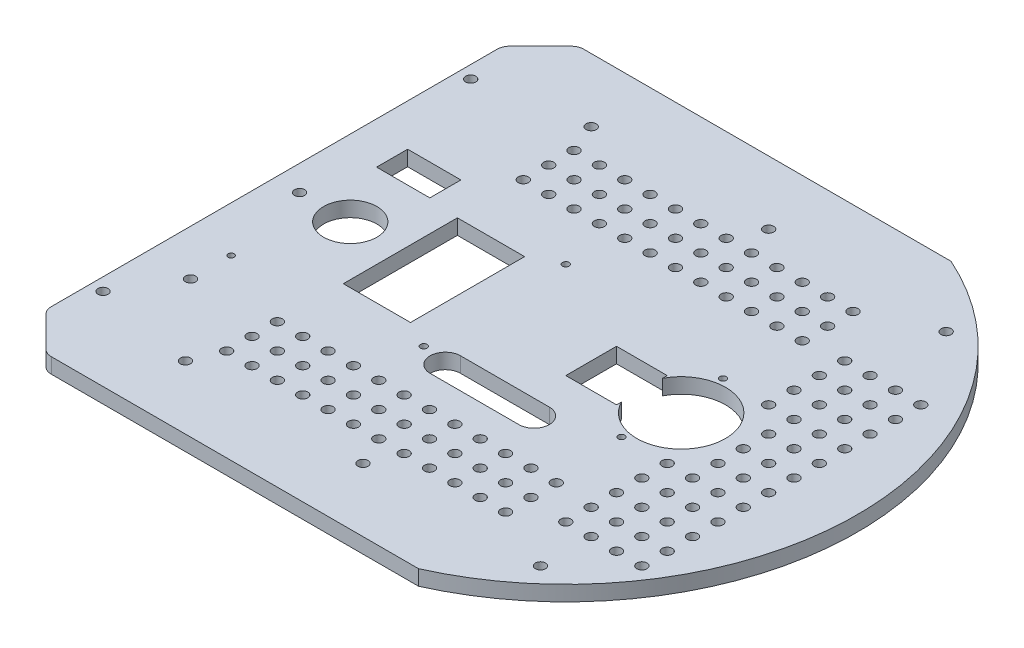
from build123d import *

# Parameters (mm, degrees)
SKETCH1_R           = 2
BOSS_EXTRUDE1_DEPTH = 6
SKETCH2_R           = 1.3
SKETCH2_R_2         = 10.5
SKETCH2_R_3         = 1.2
SKETCH2_R_4         = 2
SKETCH2_R_5         = 17.5
SKETCH2_W           = 26.5
SKETCH2_H           = 45
CUT_EXTRUDE1_DEPTH  = 10
BOSS_EXTRUDE2_DEPTH = 6
CHAMFER1_SIZE       = 15
FILLET1_R           = 5
SKETCH4_R           = 2
CUT_EXTRUDE2_DEPTH  = 10
SKETCH5_W           = 21
SKETCH5_H           = 12.25
CUT_EXTRUDE3_DEPTH  = 10
SKETCH6_W           = 20
SKETCH6_H           = 20
CUT_EXTRUDE4_DEPTH  = 10


with BuildPart() as part:
    # Sketch1 → Boss-Extrude1 (new body)
    with BuildSketch(Plane(origin=(0, 0, 0), x_dir=(1, 0, 0), z_dir=(0, 1, 0))):
        with BuildLine():
            Line((-46.904157598, -105), (46.904157598, -105))
            ThreePointArc((46.904157598, -105), (115, 0), (46.904157598, 105))
            Line((46.904157598, 105), (-46.904157598, 105))
            ThreePointArc((-46.904157598, 105), (-115, 0), (-46.904157598, -105))
        make_face()
        with Locations((-70, 80)):
            Circle(SKETCH1_R, mode=Mode.SUBTRACT)
        with Locations((70, 80)):
            Circle(SKETCH1_R, mode=Mode.SUBTRACT)
        with Locations((70, -80)):
            Circle(SKETCH1_R, mode=Mode.SUBTRACT)
        with Locations((-70, -80)):
            Circle(SKETCH1_R, mode=Mode.SUBTRACT)
        with Locations((0, 80)):
            Circle(SKETCH1_R, mode=Mode.SUBTRACT)
        with Locations((70, 0)):
            Circle(SKETCH1_R, mode=Mode.SUBTRACT)
        with Locations((0, -80)):
            Circle(SKETCH1_R, mode=Mode.SUBTRACT)
    extrude(amount=BOSS_EXTRUDE1_DEPTH)

    # Sketch2 → Cut-Extrude1 (cut)
    with BuildSketch(Plane(origin=(0, 6, 0), x_dir=(1, 0, 0), z_dir=(0, 1, 0))):
        with Locations((-28, 28)):
            Circle(SKETCH2_R)
        with Locations((-28, -28)):
            Circle(SKETCH2_R)
        with Locations((42, 20)):
            Circle(SKETCH2_R)
        with Locations((42, -20)):
            Circle(SKETCH2_R)
        with Locations((-85, 0)):
            Circle(SKETCH2_R_2)
        with Locations((-97, -35)):
            Circle(SKETCH2_R_3)
        with Locations((-97, -51)):
            Circle(SKETCH2_R_4)
        with Locations((-105, 0)):
            Circle(SKETCH2_R_4)
        with Locations((60, 50)):
            Circle(SKETCH2_R_4)
        with Locations((70, 50)):
            Circle(SKETCH2_R_4)
        with Locations((80, 50)):
            Circle(SKETCH2_R_4)
        with Locations((90, 50)):
            Circle(SKETCH2_R_4)
        with Locations((70, 40)):
            Circle(SKETCH2_R_4)
        with Locations((80, 40)):
            Circle(SKETCH2_R_4)
        with Locations((90, 40)):
            Circle(SKETCH2_R_4)
        with Locations((70, 30)):
            Circle(SKETCH2_R_4)
        with Locations((80, 30)):
            Circle(SKETCH2_R_4)
        with Locations((90, 30)):
            Circle(SKETCH2_R_4)
        with Locations((70, 20)):
            Circle(SKETCH2_R_4)
        with Locations((80, 20)):
            Circle(SKETCH2_R_4)
        with Locations((90, 20)):
            Circle(SKETCH2_R_4)
        with Locations((70, 10)):
            Circle(SKETCH2_R_4)
        with Locations((80, 10)):
            Circle(SKETCH2_R_4)
        with Locations((90, 10)):
            Circle(SKETCH2_R_4)
        with Locations((70, 0)):
            Circle(SKETCH2_R_4)
        with Locations((80, 0)):
            Circle(SKETCH2_R_4)
        with Locations((90, 0)):
            Circle(SKETCH2_R_4)
        with Locations((70, -10)):
            Circle(SKETCH2_R_4)
        with Locations((80, -10)):
            Circle(SKETCH2_R_4)
        with Locations((90, -10)):
            Circle(SKETCH2_R_4)
        with Locations((70, -20)):
            Circle(SKETCH2_R_4)
        with Locations((80, -20)):
            Circle(SKETCH2_R_4)
        with Locations((90, -20)):
            Circle(SKETCH2_R_4)
        with Locations((70, -30)):
            Circle(SKETCH2_R_4)
        with Locations((80, -30)):
            Circle(SKETCH2_R_4)
        with Locations((90, -30)):
            Circle(SKETCH2_R_4)
        with Locations((70, -40)):
            Circle(SKETCH2_R_4)
        with Locations((80, -40)):
            Circle(SKETCH2_R_4)
        with Locations((90, -40)):
            Circle(SKETCH2_R_4)
        with Locations((70, -50)):
            Circle(SKETCH2_R_4)
        with Locations((80, -50)):
            Circle(SKETCH2_R_4)
        with Locations((90, -50)):
            Circle(SKETCH2_R_4)
        with Locations((70, -60)):
            Circle(SKETCH2_R_4)
        with Locations((80, -60)):
            Circle(SKETCH2_R_4)
        with Locations((90, -60)):
            Circle(SKETCH2_R_4)
        with Locations((60, 40)):
            Circle(SKETCH2_R_4)
        with Locations((60, 30)):
            Circle(SKETCH2_R_4)
        with Locations((60, 20)):
            Circle(SKETCH2_R_4)
        with Locations((60, -20)):
            Circle(SKETCH2_R_4)
        with Locations((60, -30)):
            Circle(SKETCH2_R_4)
        with Locations((60, -40)):
            Circle(SKETCH2_R_4)
        with Locations((60, -50)):
            Circle(SKETCH2_R_4)
        with Locations((60, -60)):
            Circle(SKETCH2_R_4)
        with Locations((-65.25, -68.5)):
            Circle(SKETCH2_R_4)
        with Locations((34.75, 48.5)):
            Circle(SKETCH2_R_4)
        with Locations((-55.25, -68.5)):
            Circle(SKETCH2_R_4)
        with Locations((-45.25, -68.5)):
            Circle(SKETCH2_R_4)
        with Locations((-35.25, -68.5)):
            Circle(SKETCH2_R_4)
        with Locations((-25.25, -68.5)):
            Circle(SKETCH2_R_4)
        with Locations((-15.25, -68.5)):
            Circle(SKETCH2_R_4)
        with Locations((-5.25, -68.5)):
            Circle(SKETCH2_R_4)
        with Locations((4.75, -68.5)):
            Circle(SKETCH2_R_4)
        with Locations((14.75, -68.5)):
            Circle(SKETCH2_R_4)
        with Locations((24.75, -68.5)):
            Circle(SKETCH2_R_4)
        with Locations((34.75, -68.5)):
            Circle(SKETCH2_R_4)
        with Locations((44.75, -68.5)):
            Circle(SKETCH2_R_4)
        with Locations((-55.25, -58.5)):
            Circle(SKETCH2_R_4)
        with Locations((-45.25, -58.5)):
            Circle(SKETCH2_R_4)
        with Locations((-35.25, -58.5)):
            Circle(SKETCH2_R_4)
        with Locations((-25.25, -58.5)):
            Circle(SKETCH2_R_4)
        with Locations((-15.25, -58.5)):
            Circle(SKETCH2_R_4)
        with Locations((-5.25, -58.5)):
            Circle(SKETCH2_R_4)
        with Locations((4.75, -58.5)):
            Circle(SKETCH2_R_4)
        with Locations((14.75, -58.5)):
            Circle(SKETCH2_R_4)
        with Locations((24.75, -58.5)):
            Circle(SKETCH2_R_4)
        with Locations((34.75, -58.5)):
            Circle(SKETCH2_R_4)
        with Locations((44.75, -58.5)):
            Circle(SKETCH2_R_4)
        with Locations((-55.25, -48.5)):
            Circle(SKETCH2_R_4)
        with Locations((-45.25, -48.5)):
            Circle(SKETCH2_R_4)
        with Locations((-35.25, -48.5)):
            Circle(SKETCH2_R_4)
        with Locations((-25.25, -48.5)):
            Circle(SKETCH2_R_4)
        with Locations((-15.25, -48.5)):
            Circle(SKETCH2_R_4)
        with Locations((-5.25, -48.5)):
            Circle(SKETCH2_R_4)
        with Locations((4.75, -48.5)):
            Circle(SKETCH2_R_4)
        with Locations((14.75, -48.5)):
            Circle(SKETCH2_R_4)
        with Locations((24.75, -48.5)):
            Circle(SKETCH2_R_4)
        with Locations((34.75, -48.5)):
            Circle(SKETCH2_R_4)
        with Locations((44.75, -48.5)):
            Circle(SKETCH2_R_4)
        with Locations((-65.25, -58.5)):
            Circle(SKETCH2_R_4)
        with Locations((-65.25, -48.5)):
            Circle(SKETCH2_R_4)
        with Locations((44.75, 48.5)):
            Circle(SKETCH2_R_4)
        with Locations((44.75, 58.5)):
            Circle(SKETCH2_R_4)
        with Locations((34.75, 58.5)):
            Circle(SKETCH2_R_4)
        with Locations((34.75, 68.5)):
            Circle(SKETCH2_R_4)
        with Locations((44.75, 68.5)):
            Circle(SKETCH2_R_4)
        with Locations((24.75, 48.5)):
            Circle(SKETCH2_R_4)
        with Locations((24.75, 58.5)):
            Circle(SKETCH2_R_4)
        with Locations((24.75, 68.5)):
            Circle(SKETCH2_R_4)
        with Locations((14.75, 68.5)):
            Circle(SKETCH2_R_4)
        with Locations((14.75, 58.5)):
            Circle(SKETCH2_R_4)
        with Locations((14.75, 48.5)):
            Circle(SKETCH2_R_4)
        with Locations((4.75, 48.5)):
            Circle(SKETCH2_R_4)
        with Locations((4.75, 58.5)):
            Circle(SKETCH2_R_4)
        with Locations((4.75, 68.5)):
            Circle(SKETCH2_R_4)
        with Locations((-5.25, 68.5)):
            Circle(SKETCH2_R_4)
        with Locations((-5.25, 58.5)):
            Circle(SKETCH2_R_4)
        with Locations((-5.25, 48.5)):
            Circle(SKETCH2_R_4)
        with Locations((-15.25, 48.5)):
            Circle(SKETCH2_R_4)
        with Locations((-15.25, 58.5)):
            Circle(SKETCH2_R_4)
        with Locations((-15.25, 68.5)):
            Circle(SKETCH2_R_4)
        with Locations((-25.25, 68.5)):
            Circle(SKETCH2_R_4)
        with Locations((-25.25, 58.5)):
            Circle(SKETCH2_R_4)
        with Locations((-25.25, 48.5)):
            Circle(SKETCH2_R_4)
        with Locations((-35.25, 48.5)):
            Circle(SKETCH2_R_4)
        with Locations((-35.25, 68.5)):
            Circle(SKETCH2_R_4)
        with Locations((-35.25, 58.5)):
            Circle(SKETCH2_R_4)
        with Locations((-45.25, 68.5)):
            Circle(SKETCH2_R_4)
        with Locations((-45.25, 58.5)):
            Circle(SKETCH2_R_4)
        with Locations((-45.25, 48.5)):
            Circle(SKETCH2_R_4)
        with Locations((-55.25, 48.5)):
            Circle(SKETCH2_R_4)
        with Locations((-55.25, 58.5)):
            Circle(SKETCH2_R_4)
        with Locations((-55.25, 68.5)):
            Circle(SKETCH2_R_4)
        with Locations((-65.25, 68.5)):
            Circle(SKETCH2_R_4)
        with Locations((-65.25, 48.5)):
            Circle(SKETCH2_R_4)
        with Locations((-65.25, 58.5)):
            Circle(SKETCH2_R_4)
        with Locations((45.5, 0)):
            Circle(SKETCH2_R_5)
        with Locations((-52, 0)):
            Rectangle(SKETCH2_W, SKETCH2_H)
        with BuildLine():
            Line((-17.5, -24), (17.5, -24))
            ThreePointArc((17.5, -24), (23.5, -30), (17.5, -36))
            Line((17.5, -36), (-17.5, -36))
            ThreePointArc((-17.5, -36), (-23.5, -30), (-17.5, -24))
        make_face()
    extrude(amount=-CUT_EXTRUDE1_DEPTH, mode=Mode.SUBTRACT)

    # Sketch3 → Boss-Extrude2 (add)
    with BuildSketch(Plane(origin=(0, 6, 0), x_dir=(1, 0, 0), z_dir=(0, 1, 0))):
        with BuildLine():
            ThreePointArc((-115, 0), (-96.485693561, 62.574043645), (-46.904157598, 105))
            Line((-46.904157598, 105), (-115, 105))
            Line((-115, 105), (-115, 0))
        make_face()
        with BuildLine():
            ThreePointArc((-46.904157598, -105), (-96.485693561, -62.574043645), (-115, 0))
            Line((-115, 0), (-115, -105))
            Line((-115, -105), (-46.904157598, -105))
        make_face()
    extrude(amount=-BOSS_EXTRUDE2_DEPTH)

    # Chamfer1
    chamfer1_edges = [part.edges().sort_by_distance(p)[0] for p in [
        (-115, 3, -105),
        (-115, 3, 105),
    ]]
    chamfer(chamfer1_edges, length=CHAMFER1_SIZE)

    # Fillet1
    fillet1_edges = [part.edges().sort_by_distance(p)[0] for p in [
        (-100, 3, -105),
        (-115, 3, 90),
        (-115, 3, -90),
        (-100, 3, 105),
    ]]
    fillet(fillet1_edges, radius=FILLET1_R)

    # Sketch4 → Cut-Extrude2 (cut)
    with BuildSketch(Plane(origin=(0, 6, 0), x_dir=(1, 0, 0), z_dir=(0, 1, 0))):
        with Locations((-110, 72.5)):
            Circle(SKETCH4_R)
        with Locations((-110, -72.5)):
            Circle(SKETCH4_R)
    extrude(amount=-CUT_EXTRUDE2_DEPTH, mode=Mode.SUBTRACT)

    # Sketch5 → Cut-Extrude3 (cut)
    with BuildSketch(Plane(origin=(0, 6, 0), x_dir=(1, 0, 0), z_dir=(0, 1, 0))):
        with Locations((-88, 30)):
            Rectangle(SKETCH5_W, SKETCH5_H)
    extrude(amount=-CUT_EXTRUDE3_DEPTH, mode=Mode.SUBTRACT)

    # Sketch6 → Cut-Extrude4 (cut)
    with BuildSketch(Plane(origin=(0, 6, 0), x_dir=(1, 0, 0), z_dir=(0, 1, 0))):
        with Locations((20, 0)):
            Rectangle(SKETCH6_W, SKETCH6_H)
    extrude(amount=-CUT_EXTRUDE4_DEPTH, mode=Mode.SUBTRACT)


solid = part.part
